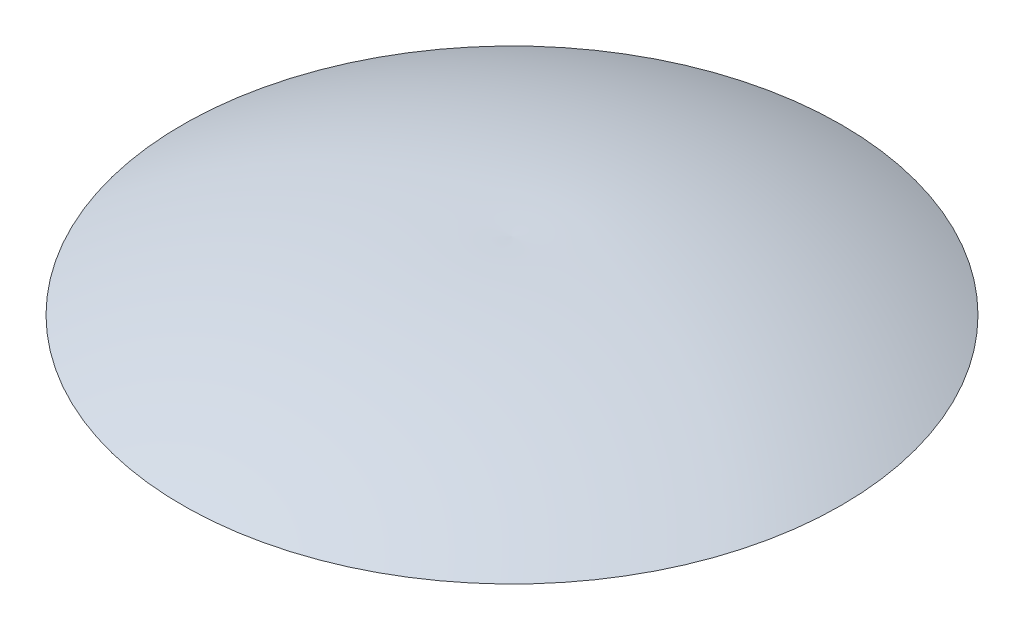
from build123d import *

# Parameters (mm, degrees)
F_5_8_11_TAPPED_HOLE1_D            = 13.49248
F_5_8_11_TAPPED_HOLE1_DEPTH        = 19.05
F_5_8_11_TAPPED_HOLE1_TIP          = 4.053549943
F_3_16_0_1875_DIAMETER_HOLE1_D     = 4.7625
F_3_16_0_1875_DIAMETER_HOLE1_DEPTH = 12.7
F_3_16_0_1875_DIAMETER_HOLE1_TIP   = 1.430799349


with BuildPart() as part:
    # Sketch1 → Revolve1 (revolve)
    with BuildSketch(Plane.XY):
        with BuildLine():
            Line((0, 0), (34.925, 0))
            Line((34.925, 0), (44.45, 12.7))
            add(Edge.make_bspline(
                [(44.45, 12.7), (69.750610432, 18.159935057), (92.075, 31.75)],
                knots=[0, 0, 0, 1, 1, 1], degree=2))
            add(Edge.make_bspline(
                [(92.075, 31.75), (49.236918404, 53.116611797), (0, 50.8)],
                knots=[0, 0, 0, 1, 1, 1], degree=2))
            Line((0, 50.8), (0, 31.75))
            Line((0, 31.75), (0, 12.7))
            Line((0, 12.7), (0, 0))
        make_face()
    revolve(axis=Axis((0, 31.75, 0), (0, 1, 0)))

    # 5/8-11 Tapped Hole1
    with Locations(Plane(origin=(0, 0, 0), x_dir=(-1, 0, 0), z_dir=(0, -1, 0))):
        with Locations((0, 0)):
            Hole(F_5_8_11_TAPPED_HOLE1_D / 2, depth=F_5_8_11_TAPPED_HOLE1_DEPTH)
            with Locations((0, 0, -(F_5_8_11_TAPPED_HOLE1_DEPTH + F_5_8_11_TAPPED_HOLE1_TIP / 2))):  # 118° drill point
                Cone(0, F_5_8_11_TAPPED_HOLE1_D / 2, F_5_8_11_TAPPED_HOLE1_TIP, mode=Mode.SUBTRACT)

    # 3/16 (0.1875) Diameter Hole1
    with Locations(Plane(origin=(-39.246742436, 5.838388433, 2.116889387), x_dir=(0.600557743, -0.799581389, 0), z_dir=(-0.798838811, -0.6, 0.043087739))):
        with Locations((0, 0)):
            Hole(F_3_16_0_1875_DIAMETER_HOLE1_D / 2, depth=F_3_16_0_1875_DIAMETER_HOLE1_DEPTH)
            with Locations((0, 0, -(F_3_16_0_1875_DIAMETER_HOLE1_DEPTH + F_3_16_0_1875_DIAMETER_HOLE1_TIP / 2))):  # 118° drill point
                Cone(0, F_3_16_0_1875_DIAMETER_HOLE1_D / 2, F_3_16_0_1875_DIAMETER_HOLE1_TIP, mode=Mode.SUBTRACT)


solid = part.part
